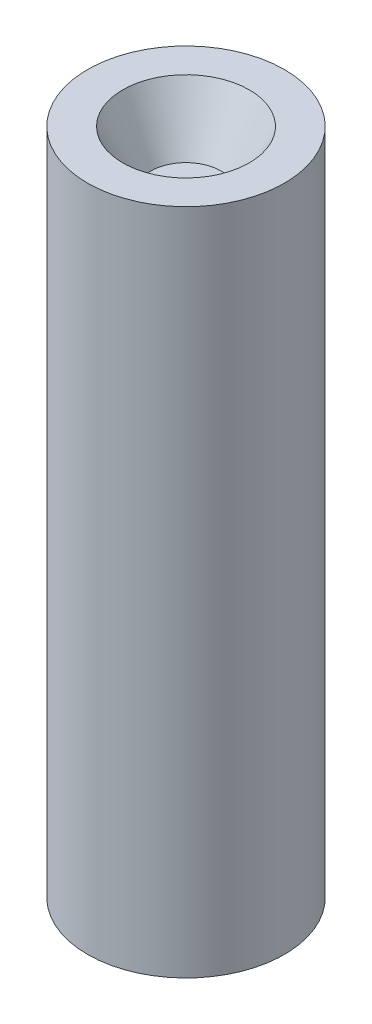
from build123d import *


with BuildPart() as part:
    # Sketch1 → Revolve1 (revolve)
    with BuildSketch(Plane.XY):
        Polygon((0, 0), (1.4, 0), (1.4, 9.5), (0.9, 9.5), (0.5, 8.7), (0, 8.7), align=None)
    revolve(axis=Axis((0, 0, 0), (0, 1, 0)))


solid = part.part
